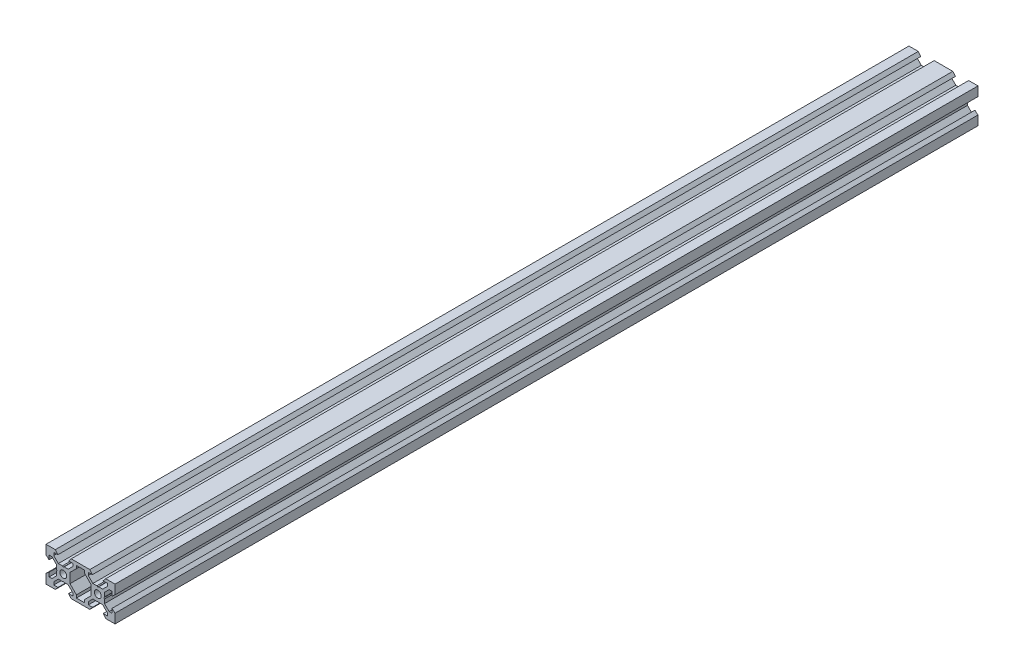
from build123d import *

# Parameters (mm, degrees)
SKETCH1_R           = 2
BOSS_EXTRUDE1_DEPTH = 500


with BuildPart() as part:
    # Sketch1 → Boss-Extrude1 (new body)
    with BuildSketch(Plane.XY):
        Polygon((-5.389620664, 10), (5.389620664, 10), (6.9, 8.2), (4.5, 8.2), (4.5, 6.556171609), (7.151917065, 3.899773171), (9.480384758, 3.899773171), (10, 3.599773171), (10.519615242, 3.899773171), (12.848082935, 3.899773171), (15.5, 6.556171609), (15.5, 8.2), (13.1, 8.2), (14.610379336, 10), (20, 10), (20, 4.610379336), (18.2, 3.1), (18.2, 5.5), (16.556171609, 5.5), (13.9, 2.839339828), (13.9, 0.519615231), (13.599999981, 0), (13.9, -0.519615231), (13.9, -2.839339828), (16.556171609, -5.5), (18.2, -5.5), (18.2, -3.1), (20, -4.610379336), (20, -10), (14.610379336, -10), (13.1, -8.2), (15.5, -8.2), (15.5, -6.556171609), (12.839339828, -3.9), (10.519222362, -3.9), (10, -3.600226829), (9.480777638, -3.9), (7.160660172, -3.9), (4.5, -6.556171609), (4.5, -8.2), (6.9, -8.2), (5.389620664, -10), (-5.389620664, -10), (-6.9, -8.2), (-4.5, -8.2), (-4.5, -6.556171609), (-7.160432959, -3.900226829), (-9.480384758, -3.900226829), (-10, -3.600226829), (-10.519615242, -3.900226829), (-12.839339828, -3.9), (-15.5, -6.556171609), (-15.5, -8.2), (-13.1, -8.2), (-14.610379336, -10), (-20, -10), (-20, -4.610379336), (-18.2, -3.1), (-18.2, -5.5), (-16.556171609, -5.5), (-13.9, -2.839339828), (-13.9, -0.519615231), (-13.599999981, 0), (-13.9, 0.519615231), (-13.9, 2.839339828), (-16.556171609, 5.5), (-18.2, 5.5), (-18.2, 3.1), (-20, 4.610379336), (-20, 10), (-14.610379336, 10), (-13.1, 8.2), (-15.5, 8.2), (-15.5, 6.556171609), (-12.839339828, 3.9), (-10.519615242, 3.899773171), (-10, 3.599773171), (-9.480384758, 3.899773171), (-7.160660172, 3.9), (-4.5, 6.556171609), (-4.5, 8.2), (-6.9, 8.2), align=None)
        with Locations((-10, 0)):
            Circle(SKETCH1_R, mode=Mode.SUBTRACT)
        with Locations((10, 0)):
            Circle(SKETCH1_R, mode=Mode.SUBTRACT)
        Polygon((-6.1, -2.839339828), (-2.376887287, -6.556171609), (-2.376887287, -8.2), (2.376887287, -8.2), (2.376887287, -6.556171609), (6.1, -2.839339828), (6.1, 2.839339828), (2.383168219, 6.556171609), (2.383168219, 8.2), (-2.383168219, 8.2), (-2.383168219, 6.556171609), (-6.1, 2.839339828), align=None, mode=Mode.SUBTRACT)
    extrude(amount=BOSS_EXTRUDE1_DEPTH)


solid = part.part
